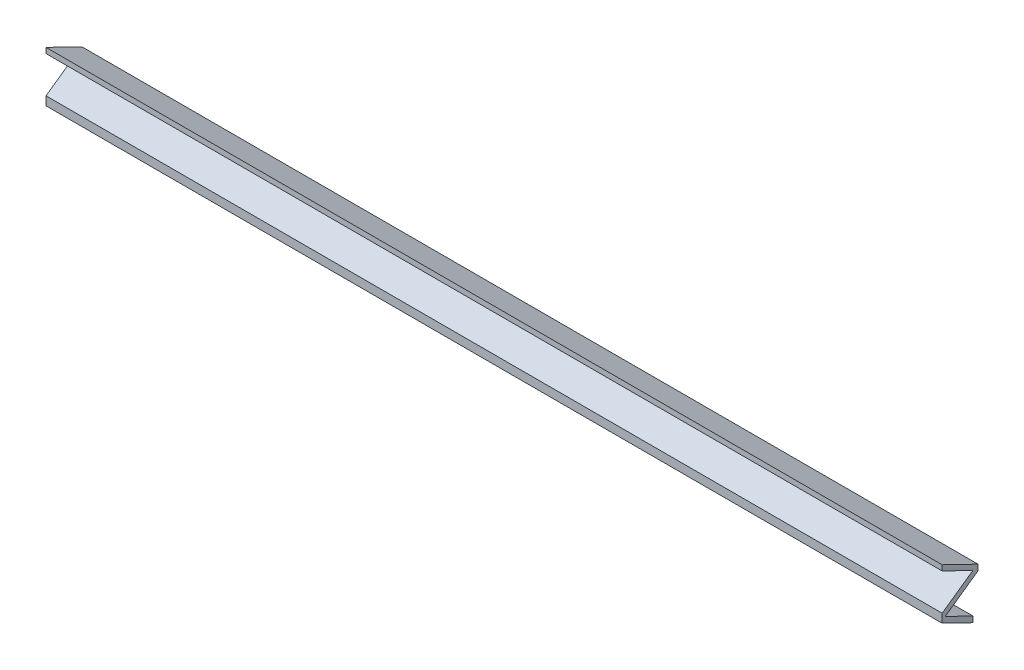
from build123d import *

# Parameters (mm, degrees)
BOSS_EXTRUDE1_DEPTH = 500


with BuildPart() as part:
    # Sketch2 → Boss-Extrude1 (new body)
    with BuildSketch(Plane(origin=(0, 0, 0), x_dir=(0, 0, -1), z_dir=(1, 0, 0))):
        Polygon((0, 0), (0, -3), (17.150234897, -11.318769416), (0, -23.397660409), (0, -28.255546443), (17.150234897, -36.574315859), (17.150234897, -33.321782597), (1.697939377, -25.826603426), (20, -12.93648288), (20, -9.701055951), align=None)
    extrude(amount=BOSS_EXTRUDE1_DEPTH)


solid = part.part
